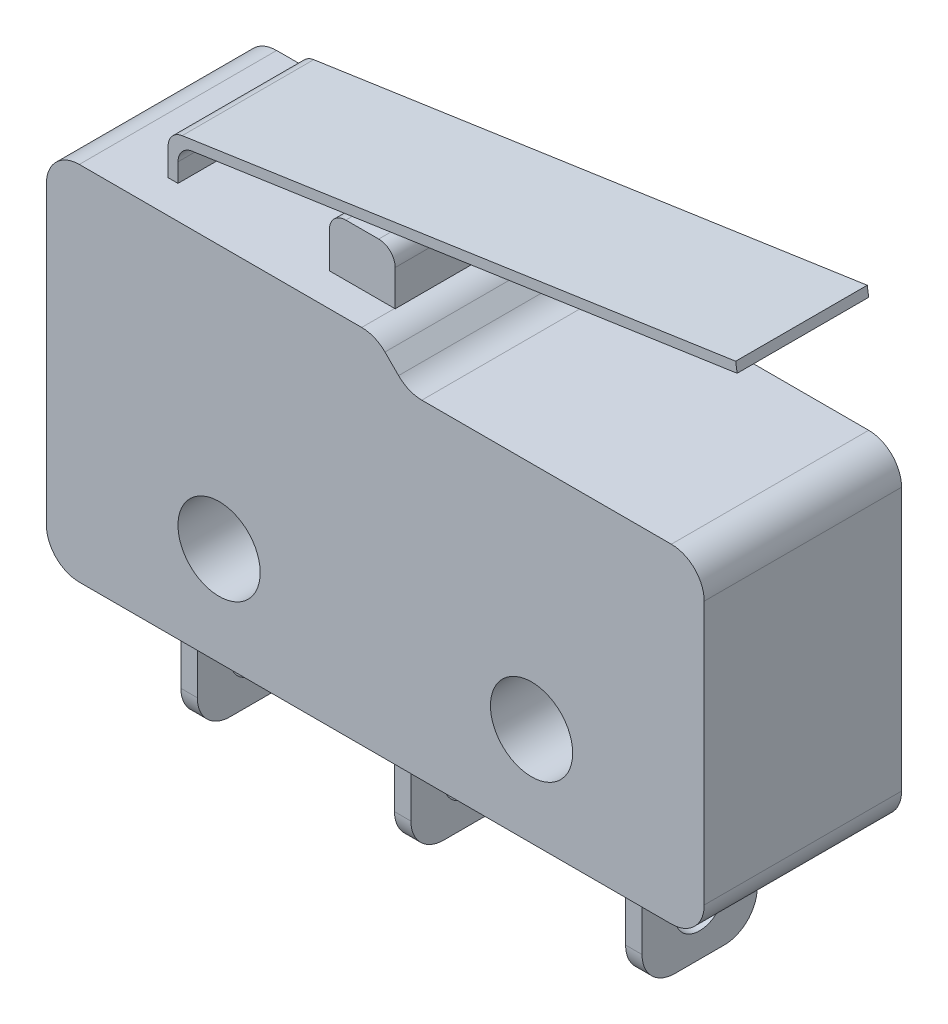
from build123d import *

# Parameters (mm, degrees)
BOSS_EXTRUDE1_DEPTH            = 4
BOSS_EXTRUDE2_DEPTH            = 1
CUT_EXTRUDE1_DEPTH             = 1
SKETCH4_W                      = 8.3
SKETCH4_H                      = 5
BOSS_EXTRUDE3_DEPTH            = 10
SKETCH5_W                      = 4
SKETCH5_H                      = 0.3
BOSS_EXTRUDE4_DEPTH            = 17.182840277
SKETCH6_W                      = 5
SKETCH6_H                      = 10
BOSS_EXTRUDE5_DEPTH            = 9
SKETCH7_W                      = 5
SKETCH7_H                      = 11
BOSS_EXTRUDE6_DEPTH            = 2.7
BOSS_EXTRUDE7_DEPTH            = 1
SKETCH9_W                      = 2
SKETCH9_H                      = 4
BOSS_EXTRUDE8_DEPTH            = 1.58656304
SKETCH10_W                     = 0.5
SKETCH10_H                     = 3.5
BOSS_EXTRUDE9_DEPTH            = 3.5
SKETCH11_W                     = 0.5
SKETCH11_H                     = 3.5
BOSS_EXTRUDE10_DEPTH           = 3.5
SKETCH12_W                     = 0.5
SKETCH12_H                     = 3.5
BOSS_EXTRUDE11_DEPTH           = 3.5
F_2_5_2_5_DIAMETER_HOLE1_D     = 2.5
F_2_5_2_5_DIAMETER_HOLE1_DEPTH = 6
F_1_5_1_5_DIAMETER_HOLE1_D     = 1.5
F_1_5_1_5_DIAMETER_HOLE1_DEPTH = 3.337462294
F_1_5_1_5_DIAMETER_HOLE2_D     = 1.5
F_1_5_1_5_DIAMETER_HOLE2_DEPTH = 3.641193774
F_1_5_1_5_DIAMETER_HOLE3_D     = 1.5
F_1_5_1_5_DIAMETER_HOLE3_DEPTH = 10.667359759
FILLET1_R                      = 0.5
FILLET2_R                      = 1


with BuildPart() as part:
    # Sketch1 → Boss-Extrude1 (new body)
    with BuildSketch(Plane(origin=(0, 0, 1), x_dir=(-1, 0, 0), z_dir=(0, 0, -1))):
        with BuildLine():
            Line((4.743251359, 8.08281548), (4.036144578, 7.375708699))
            Line((4.036144578, 7.375708699), (12.336144578, 7.375708699))
            Line((12.336144578, 7.375708699), (12.336144578, 9.634817645))
            Line((12.336144578, 9.634817645), (12.079792775, 9.67251644))
            Line((12.079792775, 9.67251644), (12.036144578, 9.375708699))
            Line((12.036144578, 9.375708699), (12.036144578, 8.375708699))
            Line((12.036144578, 8.375708699), (5.450358141, 8.375708699))
            ThreePointArc((5.450358141, 8.375708699), (5.067674708, 8.299588231), (4.743251359, 8.08281548))
        make_face()
    extrude(amount=-BOSS_EXTRUDE1_DEPTH)

    # Sketch2 → Boss-Extrude2 (add)
    with BuildSketch(Plane.XY.offset(5)):
        with BuildLine():
            Line((-12.336144578, 7.375708699), (-12.336144578, 9.634817645))
            Line((-12.336144578, 9.634817645), (-12.079792775, 9.67251644))
            Line((-12.079792775, 9.67251644), (-12.036144578, 9.375708699))
            Line((-12.036144578, 9.375708699), (-12.036144578, 8.375708699))
            Line((-12.036144578, 8.375708699), (-5.450358141, 8.375708699))
            ThreePointArc((-5.450358141, 8.375708699), (-5.067674708, 8.299588231), (-4.743251359, 8.08281548))
            Line((-4.743251359, 8.08281548), (-4.036144578, 7.375708699))
            Line((-4.036144578, 7.375708699), (-12.336144578, 7.375708699))
        make_face()
    extrude(amount=BOSS_EXTRUDE2_DEPTH)

    # Sketch3 → Cut-Extrude1 (cut)
    with BuildSketch(Plane.XY.offset(6)):
        Polygon((-12.036144578, 8.375708699), (-12.036144578, 9.375708699), (-12.079792775, 9.67251644), (-12.336144578, 9.634817645), (-12.336144578, 8.375708699), align=None)
    extrude(amount=-CUT_EXTRUDE1_DEPTH, mode=Mode.SUBTRACT)

    # Sketch4 → Boss-Extrude3 (add)
    with BuildSketch(Plane.XZ.offset(-7.375708699)):
        with Locations((-8.186144578, 3.5)):
            Rectangle(SKETCH4_W, SKETCH4_H)
    extrude(amount=BOSS_EXTRUDE3_DEPTH)

    # Sketch5 → Boss-Extrude4 (add)
    with BuildSketch(Plane(origin=(-10.431763466, -1.534082863, 0), x_dir=(0, 0, -1), z_dir=(0.989359135, 0.14549399, 0))):
        with Locations((-3, 11.177129757)):
            Rectangle(SKETCH5_W, SKETCH5_H)
    extrude(amount=BOSS_EXTRUDE4_DEPTH)

    # Sketch6 → Boss-Extrude5 (add)
    with BuildSketch(Plane(origin=(-4.036144578, 0, 0), x_dir=(0, 0, -1), z_dir=(1, 0, 0))):
        with Locations((-3.5, 2.375708699)):
            Rectangle(SKETCH6_W, SKETCH6_H)
    extrude(amount=BOSS_EXTRUDE5_DEPTH)

    # Sketch7 → Boss-Extrude6 (add)
    with BuildSketch(Plane.ZY.offset(12.336144578)):
        with Locations((3.5, 2.875708699)):
            Rectangle(SKETCH7_W, SKETCH7_H)
    extrude(amount=BOSS_EXTRUDE6_DEPTH)

    # Sketch8 → Boss-Extrude7 (add)
    with BuildSketch(Plane(origin=(0, 0, 1), x_dir=(-1, 0, 0), z_dir=(0, 0, -1))):
        with BuildLine():
            Line((15.036144578, 8.375708699), (15.036144578, -2.624291301))
            Line((15.036144578, -2.624291301), (-4.963855422, -2.624291301))
            Line((-4.963855422, -2.624291301), (-4.963855422, 7.375708699))
            Line((-4.963855422, 7.375708699), (4.036144578, 7.375708699))
            Line((4.036144578, 7.375708699), (4.743251359, 8.08281548))
            ThreePointArc((4.743251359, 8.08281548), (5.067674708, 8.299588231), (5.450358141, 8.375708699))
            Line((5.450358141, 8.375708699), (15.036144578, 8.375708699))
        make_face()
    extrude(amount=BOSS_EXTRUDE7_DEPTH)

    # Sketch9 → Boss-Extrude8 (add)
    with BuildSketch(Plane(origin=(0, 8.375708699, 0), x_dir=(-1, 0, 0), z_dir=(0, 1, 0))):
        with Locations((6.43261709, 3)):
            Rectangle(SKETCH9_W, SKETCH9_H)
    extrude(amount=BOSS_EXTRUDE8_DEPTH)

    # Sketch10 → Boss-Extrude9 (add)
    with BuildSketch(Plane.XZ.offset(2.624291301)):
        with Locations((-5.453504337, 3)):
            Rectangle(SKETCH10_W, SKETCH10_H)
    extrude(amount=BOSS_EXTRUDE9_DEPTH)

    # Sketch11 → Boss-Extrude10 (add)
    with BuildSketch(Plane.XZ.offset(2.624291301)):
        with Locations((1.572661648, 3)):
            Rectangle(SKETCH11_W, SKETCH11_H)
    extrude(amount=BOSS_EXTRUDE10_DEPTH)

    # Sketch12 → Boss-Extrude11 (add)
    with BuildSketch(Plane.XZ.offset(2.624291301)):
        with Locations((-11.948682285, 3)):
            Rectangle(SKETCH12_W, SKETCH12_H)
    extrude(amount=BOSS_EXTRUDE11_DEPTH)

    # Ø2.5 (2.5) Diameter Hole1
    with Locations(Plane.XY.offset(6)):
        with Locations((-9.786144578, 0.375708699), (-0.286144578, 0.375708699)):
            Hole(F_2_5_2_5_DIAMETER_HOLE1_D / 2, depth=F_2_5_2_5_DIAMETER_HOLE1_DEPTH)

    # Ø1.5 (1.5) Diameter Hole1
    with Locations(Plane(origin=(-11.698682285, 0, 0), x_dir=(0, 0, -1), z_dir=(1, 0, 0))):
        with Locations((-3, -4.624291301)):
            Hole(F_1_5_1_5_DIAMETER_HOLE1_D / 2, depth=F_1_5_1_5_DIAMETER_HOLE1_DEPTH)

    # Ø1.5 (1.5) Diameter Hole2
    with Locations(Plane.ZY.offset(-1.322661648)):
        with Locations((3, -4.624291301)):
            Hole(F_1_5_1_5_DIAMETER_HOLE2_D / 2, depth=F_1_5_1_5_DIAMETER_HOLE2_DEPTH)

    # Ø1.5 (1.5) Diameter Hole3
    with Locations(Plane.ZY.offset(5.703504337)):
        with Locations((3, -4.624291301)):
            Hole(F_1_5_1_5_DIAMETER_HOLE3_D / 2, depth=F_1_5_1_5_DIAMETER_HOLE3_DEPTH)

    # Fillet1
    fillet1_edges = [part.edges().sort_by_distance(p)[0] for p in [
        (-7.43261709, 9.962271739, 3),
        (-5.43261709, 9.962271739, 3),
        (-12.336144578, 9.634817645, 3),
        (-12.036144578, 9.375708699, 3),
    ]]
    fillet(fillet1_edges, radius=FILLET1_R)

    # Fillet2
    fillet2_edges = [part.edges().sort_by_distance(p)[0] for p in [
        (-15.036144578, -2.624291301, 3),
        (-15.036144578, 8.375708699, 3),
        (-4.036144578, 7.375708699, 3),
        (-5.453504337, -6.124291301, 1.25),
        (-5.453504337, -6.124291301, 4.75),
        (1.572661648, -6.124291301, 1.25),
        (1.572661648, -6.124291301, 4.75),
        (-11.948682285, -6.124291301, 1.25),
        (-11.948682285, -6.124291301, 4.75),
        (4.963855422, 7.375708699, 3),
        (4.963855422, -2.624291301, 3),
    ]]
    fillet(fillet2_edges, radius=FILLET2_R)


solid = part.part
